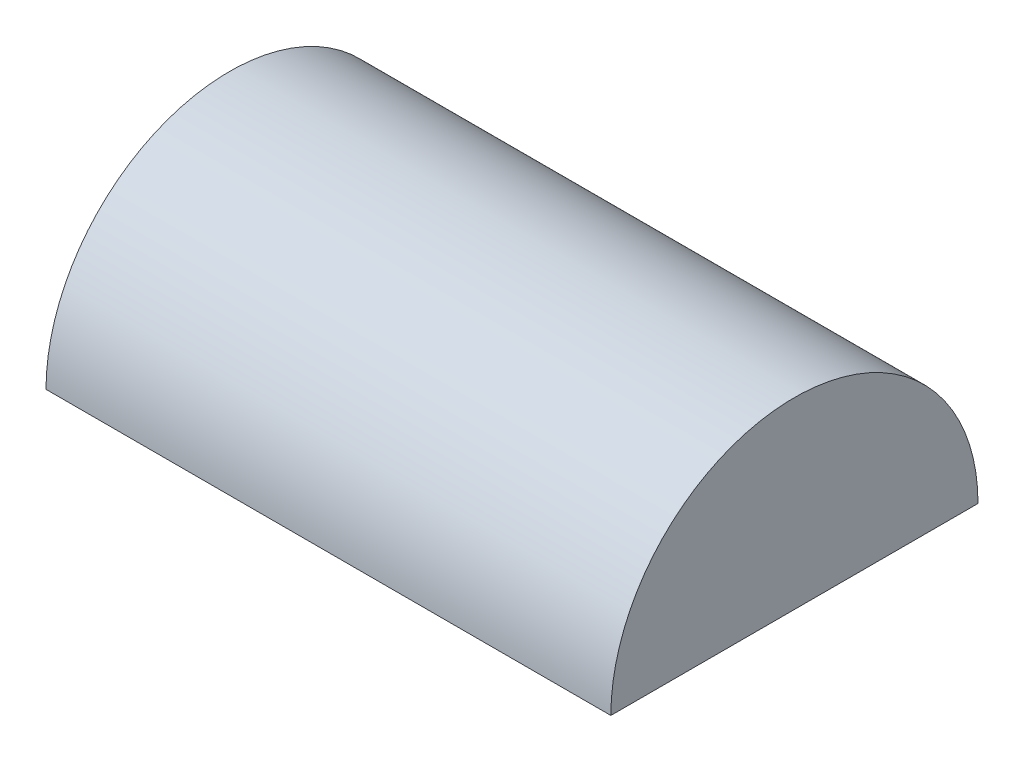
from build123d import *

# Parameters (mm, degrees)
SKETCH1_R           = 19.5
BOSS_EXTRUDE1_DEPTH = 60
SKETCH2_W           = 42.862811924
SKETCH2_H           = 22.916416769
CUT_EXTRUDE2_DEPTH  = 101


with BuildPart() as part:
    # Sketch1 → Boss-Extrude1 (new body)
    with BuildSketch(Plane(origin=(0, 0, 0), x_dir=(0, 0, -1), z_dir=(1, 0, 0))):
        Circle(SKETCH1_R)
    extrude(amount=BOSS_EXTRUDE1_DEPTH)

    # Sketch2 → Cut-Extrude2 (cut)
    with BuildSketch(Plane(origin=(0, 0, 0), x_dir=(0, 0, -1), z_dir=(1, 0, 0))):
        with Locations((0.033750246, -11.458208385)):
            Rectangle(SKETCH2_W, SKETCH2_H)
    extrude(amount=CUT_EXTRUDE2_DEPTH, mode=Mode.SUBTRACT)


solid = part.part
